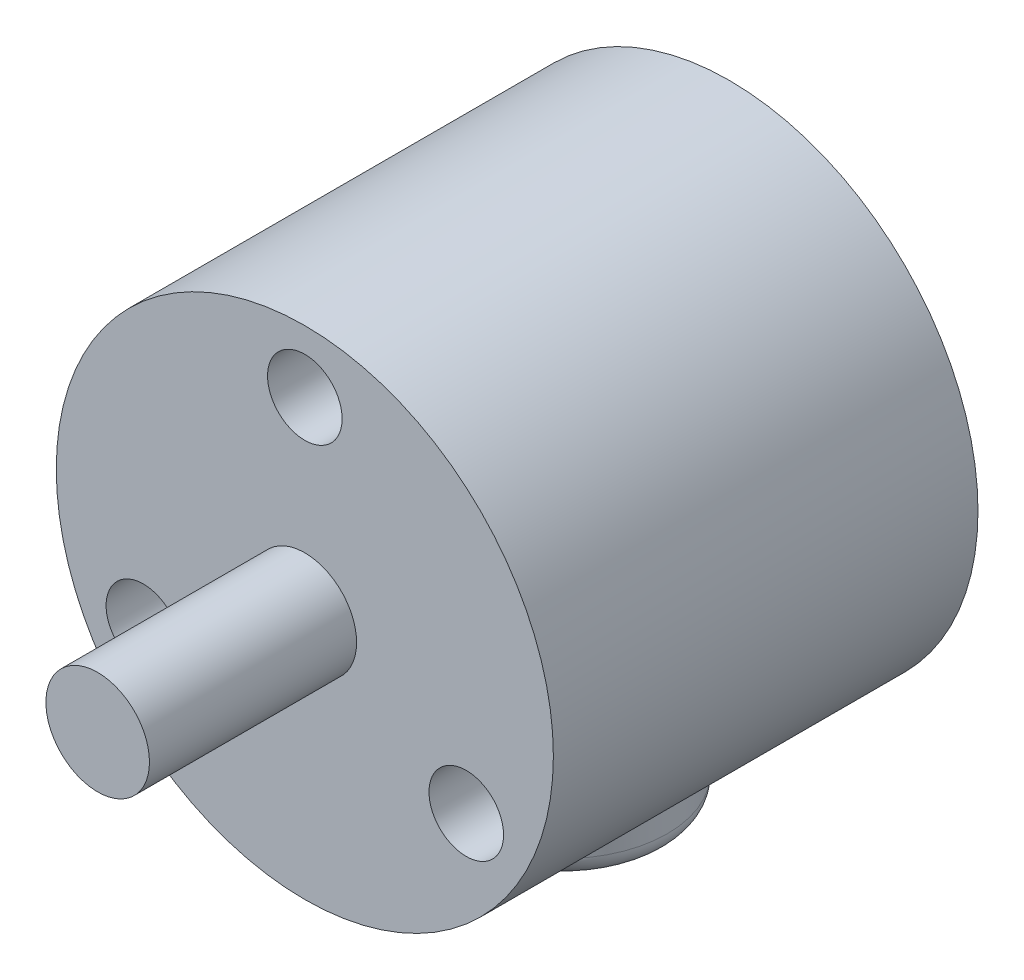
from build123d import *

# Parameters (mm, degrees)
ESQUISSE1_R             = 12
BOSS_EXTRU_1_DEPTH      = 20.5
ESQUISSE2_R             = 2.5
BOSS_EXTRU_2_DEPTH      = 3.5
ESQUISSE3_R             = 1.8
ENL_V_MAT_EXTRU_1_DEPTH = 3
ESQUISSE4_R             = 2.5
BOSS_EXTRU_3_DEPTH      = 6.5
ESQUISSE5_R             = 5
BOSS_EXTRU_4_DEPTH      = 14
CONG_1_R                = 1


with BuildPart() as part:
    # Esquisse1 → Boss.-Extru.1 (new body)
    with BuildSketch(Plane.XY):
        Circle(ESQUISSE1_R)
    extrude(amount=BOSS_EXTRU_1_DEPTH)

    # Esquisse2 → Boss.-Extru.2 (add)
    with BuildSketch(Plane.XY.offset(20.5)):
        Circle(ESQUISSE2_R)
    extrude(amount=BOSS_EXTRU_2_DEPTH)

    # Esquisse3 → Enlèv. mat.-Extru.1 (cut)
    with BuildSketch(Plane.XY.offset(20.5)):
        with Locations((0, 9)):
            Circle(ESQUISSE3_R)
        with Locations((-7.794228634, -4.5)):
            Circle(ESQUISSE3_R)
        with Locations((7.794228634, -4.5)):
            Circle(ESQUISSE3_R)
    extrude(amount=-ENL_V_MAT_EXTRU_1_DEPTH, mode=Mode.SUBTRACT)

    # Esquisse4 → Boss.-Extru.3 (add)
    with BuildSketch(Plane.XY.offset(24)):
        Circle(ESQUISSE4_R)
    extrude(amount=BOSS_EXTRU_3_DEPTH)

    # Esquisse5 → Boss.-Extru.4 (add)
    with BuildSketch(Plane(origin=(0, 0, 0), x_dir=(1, 0, 0), z_dir=(0, 1, 0))):
        with Locations((0, -8)):
            Circle(ESQUISSE5_R)
    extrude(amount=-BOSS_EXTRU_4_DEPTH)

    # Congé1
    cong_1_edges = [part.edges().sort_by_distance(p)[0] for p in [
        (-5, -14, 8),
    ]]
    fillet(cong_1_edges, radius=CONG_1_R)


solid = part.part
